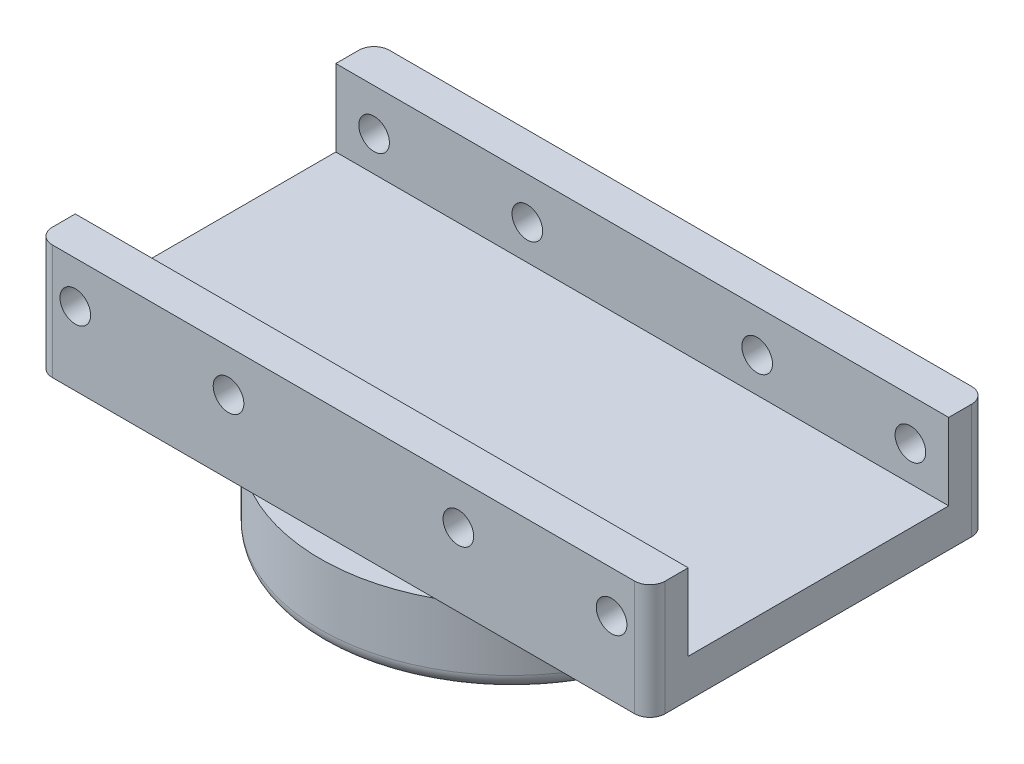
from build123d import *

# Parameters (mm, degrees)
SKETCH_1_R          = 25
EXTRUDE_1_DEPTH     = 10
SKETCH_2_R          = 10
EXTRUDE_2_DEPTH     = 10
FILLET_1_R          = 2
SKETCH_3_W          = 80
SKETCH_3_H          = 44
EXTRUDE_3_DEPTH     = 5
SKETCH_4_W          = 80
SKETCH_4_H          = 5
EXTRUDE_4_DEPTH     = 10
SKETCH_5_R          = 2
CUT_EXTRUDE_1_DEPTH = 81
FILLET_4_R          = 2


with BuildPart() as part:
    # 草圖1 → 填料-伸長1 (new body)
    with BuildSketch(Plane(origin=(0, 0, 0), x_dir=(1, 0, 0), z_dir=(0, 1, 0))):
        Circle(SKETCH_1_R)
    extrude(amount=EXTRUDE_1_DEPTH)

    # 草圖2 → 填料-伸長2 (add)
    with BuildSketch(Plane.XZ):
        Circle(SKETCH_2_R)
    extrude(amount=EXTRUDE_2_DEPTH)

    # 圓角1
    fillet_1_edges = [part.edges().sort_by_distance(p)[0] for p in [
        (-25, 0, 0),
        (-10, -10, 0),
    ]]
    fillet(fillet_1_edges, radius=FILLET_1_R)

    # 草圖3 → 填料-伸長3 (add)
    with BuildSketch(Plane(origin=(0, 10, 0), x_dir=(1, 0, 0), z_dir=(0, 1, 0))):
        Rectangle(SKETCH_3_W, SKETCH_3_H)
    extrude(amount=EXTRUDE_3_DEPTH)

    # 草圖4 → 填料-伸長4 (add)
    with BuildSketch(Plane(origin=(0, 15, 0), x_dir=(1, 0, 0), z_dir=(0, 1, 0))):
        with Locations((0, 19.5)):
            Rectangle(SKETCH_4_W, SKETCH_4_H)
        with Locations((0, -19.5)):
            Rectangle(SKETCH_4_W, SKETCH_4_H)
    extrude(amount=EXTRUDE_4_DEPTH)

    # 草圖5 → 除料-伸長1 (cut)
    with BuildSketch(Plane(origin=(0, 0, -22), x_dir=(-1, 0, 0), z_dir=(0, 0, -1))):
        with Locations((-15, 19.545082089)):
            Circle(SKETCH_5_R)
        with Locations((-35, 19.545082089)):
            Circle(SKETCH_5_R)
        with Locations((15, 19.545082089)):
            Circle(SKETCH_5_R)
        with Locations((35, 19.545082089)):
            Circle(SKETCH_5_R)
    extrude(amount=-CUT_EXTRUDE_1_DEPTH, mode=Mode.SUBTRACT)

    # 圓角4
    fillet_4_edges = [part.edges().sort_by_distance(p)[0] for p in [
        (40, 17.5, 22),
        (40, 17.5, -22),
        (-40, 17.5, -22),
        (-40, 17.5, 22),
    ]]
    fillet(fillet_4_edges, radius=FILLET_4_R)


solid = part.part
